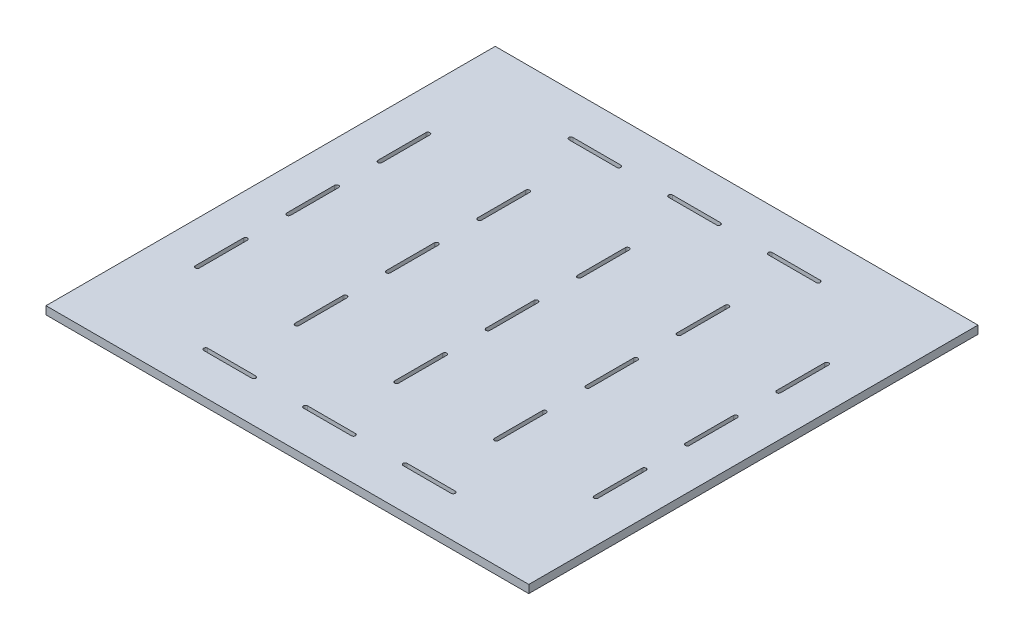
from build123d import *

# Parameters (mm, degrees)
SKETCH1_W                              = 382.775
SKETCH1_H                              = 356.150000032
BOSS_EXTRUDE1_DEPTH                    = 3.175
OUTER_SIDE_WALL_WELD_TAB_CUTOUTS_DEPTH = 6.35
CUT_EXTRUDE2_DEPTH                     = 6.35
CUT_EXTRUDE3_DEPTH                     = 6.35


with BuildPart() as part:
    # Sketch1 → Boss-Extrude1 (new body, symmetric)
    with BuildSketch(Plane(origin=(0, 0, 0), x_dir=(1, 0, 0), z_dir=(0, 1, 0))):
        with Locations((158.05, 144.737500016)):
            Rectangle(SKETCH1_W, SKETCH1_H)
    extrude(amount=BOSS_EXTRUDE1_DEPTH, both=True)

    # Sketch3 → Outer Side Wall Weld Tab Cutouts (cut)
    with BuildSketch(Plane(origin=(0, -3.175, 0), x_dir=(1, 0, 0), z_dir=(0, 1, 0))):
        with BuildLine():
            Line((314.5125, 53.318750008), (314.5125, 91.418750008))
            ThreePointArc((314.5125, 91.418750008), (316.1, 93.006250008), (317.6875, 91.418750008))
            Line((317.6875, 91.418750008), (317.6875, 53.318750008))
            ThreePointArc((317.6875, 53.318750008), (316.1, 51.731250008), (314.5125, 53.318750008))
        make_face()
        with BuildLine():
            Line((-1.5875, 53.318750008), (-1.5875, 91.418750008))
            ThreePointArc((-1.5875, 91.418750008), (0, 93.006250008), (1.5875, 91.418750008))
            Line((1.5875, 91.418750008), (1.5875, 53.318750008))
            ThreePointArc((1.5875, 53.318750008), (0, 51.731250008), (-1.5875, 53.318750008))
        make_face()
        with BuildLine():
            Line((314.5125, 125.687500016), (314.5125, 163.787500016))
            ThreePointArc((314.5125, 163.787500016), (316.1, 165.375000016), (317.6875, 163.787500016))
            Line((317.6875, 163.787500016), (317.6875, 125.687500016))
            ThreePointArc((317.6875, 125.687500016), (316.1, 124.100000016), (314.5125, 125.687500016))
        make_face()
        with BuildLine():
            Line((314.5125, 198.056250024), (314.5125, 236.156250024))
            ThreePointArc((314.5125, 236.156250024), (316.1, 237.743750024), (317.6875, 236.156250024))
            Line((317.6875, 236.156250024), (317.6875, 198.056250024))
            ThreePointArc((317.6875, 198.056250024), (316.1, 196.468750024), (314.5125, 198.056250024))
        make_face()
        with BuildLine():
            Line((-1.5875, 125.687500016), (-1.5875, 163.787500016))
            ThreePointArc((-1.5875, 163.787500016), (0, 165.375000016), (1.5875, 163.787500016))
            Line((1.5875, 163.787500016), (1.5875, 125.687500016))
            ThreePointArc((1.5875, 125.687500016), (0, 124.100000016), (-1.5875, 125.687500016))
        make_face()
        with BuildLine():
            Line((-1.5875, 198.056250024), (-1.5875, 236.156250024))
            ThreePointArc((-1.5875, 236.156250024), (0, 237.743750024), (1.5875, 236.156250024))
            Line((1.5875, 236.156250024), (1.5875, 198.056250024))
            ThreePointArc((1.5875, 198.056250024), (0, 196.468750024), (-1.5875, 198.056250024))
        make_face()
    extrude(amount=OUTER_SIDE_WALL_WELD_TAB_CUTOUTS_DEPTH, mode=Mode.SUBTRACT)

    # Sketch4 → Cut-Extrude2 (cut)
    with BuildSketch(Plane(origin=(0, -3.175, 0), x_dir=(1, 0, 0), z_dir=(0, 1, 0))):
        with BuildLine():
            Line((156.4625, 53.318750008), (156.4625, 91.418750008))
            ThreePointArc((156.4625, 91.418750008), (158.05, 93.006250008), (159.6375, 91.418750008))
            Line((159.6375, 91.418750008), (159.6375, 53.318750008))
            ThreePointArc((159.6375, 53.318750008), (158.05, 51.731250008), (156.4625, 53.318750008))
        make_face()
        with BuildLine():
            Line((77.4375, 53.318750008), (77.4375, 91.418750008))
            ThreePointArc((77.4375, 91.418750008), (79.025, 93.006250008), (80.6125, 91.418750008))
            Line((80.6125, 91.418750008), (80.6125, 53.318750008))
            ThreePointArc((80.6125, 53.318750008), (79.025, 51.731250008), (77.4375, 53.318750008))
        make_face()
        with BuildLine():
            Line((235.4875, 53.318750008), (235.4875, 91.418750008))
            ThreePointArc((235.4875, 91.418750008), (237.075, 93.006250008), (238.6625, 91.418750008))
            Line((238.6625, 91.418750008), (238.6625, 53.318750008))
            ThreePointArc((238.6625, 53.318750008), (237.075, 51.731250008), (235.4875, 53.318750008))
        make_face()
        with BuildLine():
            Line((156.4625, 125.687500016), (156.4625, 163.787500016))
            ThreePointArc((156.4625, 163.787500016), (158.05, 165.375000016), (159.6375, 163.787500016))
            Line((159.6375, 163.787500016), (159.6375, 125.687500016))
            ThreePointArc((159.6375, 125.687500016), (158.05, 124.100000016), (156.4625, 125.687500016))
        make_face()
        with BuildLine():
            Line((235.4875, 125.687500016), (235.4875, 163.787500016))
            ThreePointArc((235.4875, 163.787500016), (237.075, 165.375000016), (238.6625, 163.787500016))
            Line((238.6625, 163.787500016), (238.6625, 125.687500016))
            ThreePointArc((238.6625, 125.687500016), (237.075, 124.100000016), (235.4875, 125.687500016))
        make_face()
        with BuildLine():
            Line((156.4625, 198.056250024), (156.4625, 236.156250024))
            ThreePointArc((156.4625, 236.156250024), (158.05, 237.743750024), (159.6375, 236.156250024))
            Line((159.6375, 236.156250024), (159.6375, 198.056250024))
            ThreePointArc((159.6375, 198.056250024), (158.05, 196.468750024), (156.4625, 198.056250024))
        make_face()
        with BuildLine():
            Line((235.4875, 198.056250024), (235.4875, 236.156250024))
            ThreePointArc((235.4875, 236.156250024), (237.075, 237.743750024), (238.6625, 236.156250024))
            Line((238.6625, 236.156250024), (238.6625, 198.056250024))
            ThreePointArc((238.6625, 198.056250024), (237.075, 196.468750024), (235.4875, 198.056250024))
        make_face()
        with BuildLine():
            Line((77.4375, 125.687500016), (77.4375, 163.787500016))
            ThreePointArc((77.4375, 163.787500016), (79.025, 165.375000016), (80.6125, 163.787500016))
            Line((80.6125, 163.787500016), (80.6125, 125.687500016))
            ThreePointArc((80.6125, 125.687500016), (79.025, 124.100000016), (77.4375, 125.687500016))
        make_face()
        with BuildLine():
            Line((77.4375, 198.056250024), (77.4375, 236.156250024))
            ThreePointArc((77.4375, 236.156250024), (79.025, 237.743750024), (80.6125, 236.156250024))
            Line((80.6125, 236.156250024), (80.6125, 198.056250024))
            ThreePointArc((80.6125, 198.056250024), (79.025, 196.468750024), (77.4375, 198.056250024))
        make_face()
    extrude(amount=CUT_EXTRUDE2_DEPTH, mode=Mode.SUBTRACT)

    # Sketch5 → Cut-Extrude3 (cut)
    with BuildSketch(Plane(origin=(0, -3.175, 0), x_dir=(1, 0, 0), z_dir=(0, 1, 0))):
        with BuildLine():
            Line((139, 1.5875), (177.1, 1.5875))
            ThreePointArc((177.1, 1.5875), (178.6875, 0), (177.1, -1.5875))
            Line((177.1, -1.5875), (139, -1.5875))
            ThreePointArc((139, -1.5875), (137.4125, 0), (139, 1.5875))
        make_face()
        with BuildLine():
            Line((59.975, 1.5875), (98.075, 1.5875))
            ThreePointArc((98.075, 1.5875), (99.6625, 0), (98.075, -1.5875))
            Line((98.075, -1.5875), (59.975, -1.5875))
            ThreePointArc((59.975, -1.5875), (58.3875, 0), (59.975, 1.5875))
        make_face()
        with BuildLine():
            Line((218.025, 1.5875), (256.125, 1.5875))
            ThreePointArc((256.125, 1.5875), (257.7125, 0), (256.125, -1.5875))
            Line((256.125, -1.5875), (218.025, -1.5875))
            ThreePointArc((218.025, -1.5875), (216.4375, 0), (218.025, 1.5875))
        make_face()
        with BuildLine():
            Line((139, 291.062500032), (177.1, 291.062500032))
            ThreePointArc((177.1, 291.062500032), (178.6875, 289.475000032), (177.1, 287.887500032))
            Line((177.1, 287.887500032), (139, 287.887500032))
            ThreePointArc((139, 287.887500032), (137.4125, 289.475000032), (139, 291.062500032))
        make_face()
        with BuildLine():
            Line((218.025, 291.062500032), (256.125, 291.062500032))
            ThreePointArc((256.125, 291.062500032), (257.7125, 289.475000032), (256.125, 287.887500032))
            Line((256.125, 287.887500032), (218.025, 287.887500032))
            ThreePointArc((218.025, 287.887500032), (216.4375, 289.475000032), (218.025, 291.062500032))
        make_face()
        with BuildLine():
            Line((59.975, 291.062500032), (98.075, 291.062500032))
            ThreePointArc((98.075, 291.062500032), (99.6625, 289.475000032), (98.075, 287.887500032))
            Line((98.075, 287.887500032), (59.975, 287.887500032))
            ThreePointArc((59.975, 287.887500032), (58.3875, 289.475000032), (59.975, 291.062500032))
        make_face()
    extrude(amount=CUT_EXTRUDE3_DEPTH, mode=Mode.SUBTRACT)


solid = part.part
